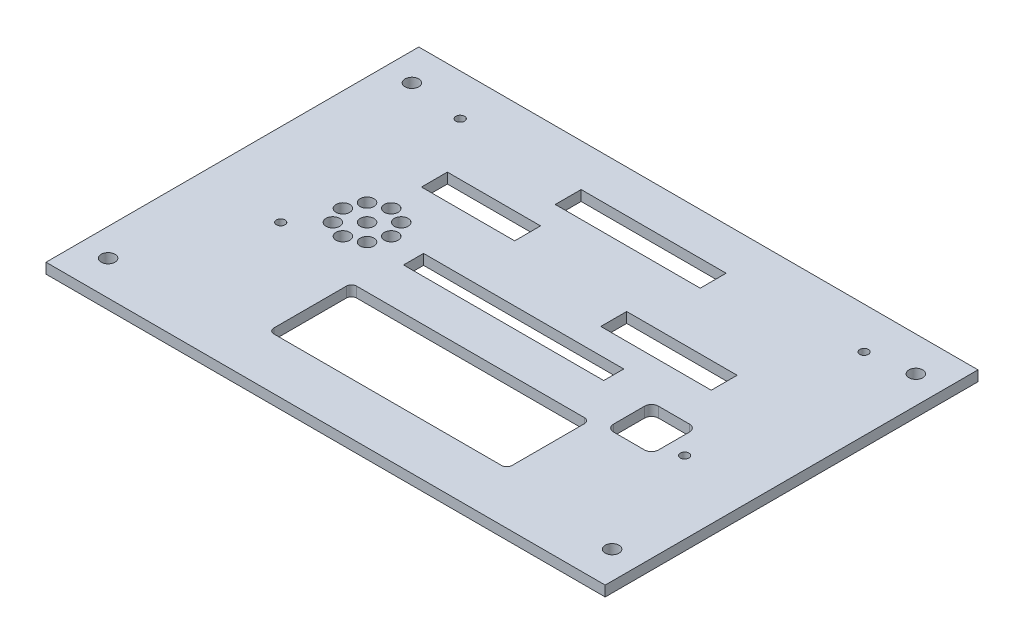
from build123d import *

# Parameters (mm, degrees)
SKETCH_1_W             = 162
SKETCH_1_H             = 108
EXTRUDE_1_DEPTH        = 3
SKETCH_2_R             = 2
SKETCH_2_W             = 42
SKETCH_2_H             = 7.5
SKETCH_2_W_2           = 27
SKETCH_2_W_3           = 32
SKETCH_2_W_4           = 58
SKETCH_2_H_2           = 5.8
SKETCH_2_W_5           = 69
SKETCH_2_H_3           = 24
SKETCH_2_W_6           = 13
SKETCH_2_H_4           = 13
CUT_EXTRUDE_2448_DEPTH = 4
FILLET_1_R             = 1.5
SKETCH_3_R             = 1.25
CUT_EXTRUDE_3312_DEPTH = 4
SKETCH_4_R             = 2
CUT_EXTRUDE_4190_DEPTH = 4
FILLET_2_R             = 2


with BuildPart() as part:
    # Эскиз1 → Бобышка-Вытянуть1 (new body)
    with BuildSketch(Plane(origin=(0, 0, 0), x_dir=(1, 0, 0), z_dir=(0, 1, 0))):
        Rectangle(SKETCH_1_W, SKETCH_1_H)
    extrude(amount=EXTRUDE_1_DEPTH)

    # Эскиз2 → Cut-Extrude 2448 (cut, through all)
    with BuildSketch(Plane(origin=(0, 3, 0), x_dir=(1, 0, 0), z_dir=(0, 1, 0))):
        with Locations((-72.99950864, 44.00008818)):
            Circle(SKETCH_2_R)
        with Locations((73, 44)):
            Circle(SKETCH_2_R)
        with Locations((-73, -44)):
            Circle(SKETCH_2_R)
        with Locations((73, -44)):
            Circle(SKETCH_2_R)
        with Locations((-0.725, 38)):
            Rectangle(SKETCH_2_W, SKETCH_2_H)
        with Locations((-31.975, 23)):
            Rectangle(SKETCH_2_W_2, SKETCH_2_H)
        with Locations((31.475, 14)):
            Rectangle(SKETCH_2_W_3, SKETCH_2_H)
        with Locations((0.475, 0)):
            Rectangle(SKETCH_2_W_4, SKETCH_2_H_2)
        with Locations((3, -27)):
            Rectangle(SKETCH_2_W_5, SKETCH_2_H_3)
        with Locations((48.316, -7.9)):
            Rectangle(SKETCH_2_W_6, SKETCH_2_H_4)
    extrude(amount=-CUT_EXTRUDE_2448_DEPTH, mode=Mode.SUBTRACT)

    # Скругление1
    fillet_1_edges = [part.edges().sort_by_distance(p)[0] for p in [
        (-31.5, 1.5, 39),
        (-31.5, 1.5, 15),
        (37.5, 1.5, 15),
        (37.5, 1.5, 39),
    ]]
    fillet(fillet_1_edges, radius=FILLET_1_R)

    # Эскиз3 → Cut-Extrude 3312 (cut, through all)
    with BuildSketch(Plane(origin=(0, 3, 0), x_dir=(1, 0, 0), z_dir=(0, 1, 0))):
        with Locations((-57, 42)):
            Circle(SKETCH_3_R)
        with Locations((-57, -10)):
            Circle(SKETCH_3_R)
        with Locations((60, 42)):
            Circle(SKETCH_3_R)
        with Locations((60, -10)):
            Circle(SKETCH_3_R)
    extrude(amount=-CUT_EXTRUDE_3312_DEPTH, mode=Mode.SUBTRACT)

    # Эскиз4 → Cut-Extrude 4190 (cut, through all)
    with BuildSketch(Plane(origin=(0, 3, 0), x_dir=(1, 0, 0), z_dir=(0, 1, 0))):
        with Locations((-44.5, 2.51)):
            Circle(SKETCH_4_R)
        with Locations((-51.5, 2.51)):
            Circle(SKETCH_4_R)
        with Locations((-49.449747468, 7.459747468)):
            Circle(SKETCH_4_R)
        with Locations((-44.5, 9.51)):
            Circle(SKETCH_4_R)
        with Locations((-39.550252532, 7.459747468)):
            Circle(SKETCH_4_R)
        with Locations((-37.5, 2.51)):
            Circle(SKETCH_4_R)
        with Locations((-39.550252532, -2.439747468)):
            Circle(SKETCH_4_R)
        with Locations((-44.5, -4.49)):
            Circle(SKETCH_4_R)
        with Locations((-49.449747468, -2.439747468)):
            Circle(SKETCH_4_R)
    extrude(amount=-CUT_EXTRUDE_4190_DEPTH, mode=Mode.SUBTRACT)

    # Скругление2
    fillet_2_edges = [part.edges().sort_by_distance(p)[0] for p in [
        (41.816, 1.5, 14.4),
        (41.816, 1.5, 1.4),
        (54.816, 1.5, 1.4),
        (54.816, 1.5, 14.4),
    ]]
    fillet(fillet_2_edges, radius=FILLET_2_R)


solid = part.part
